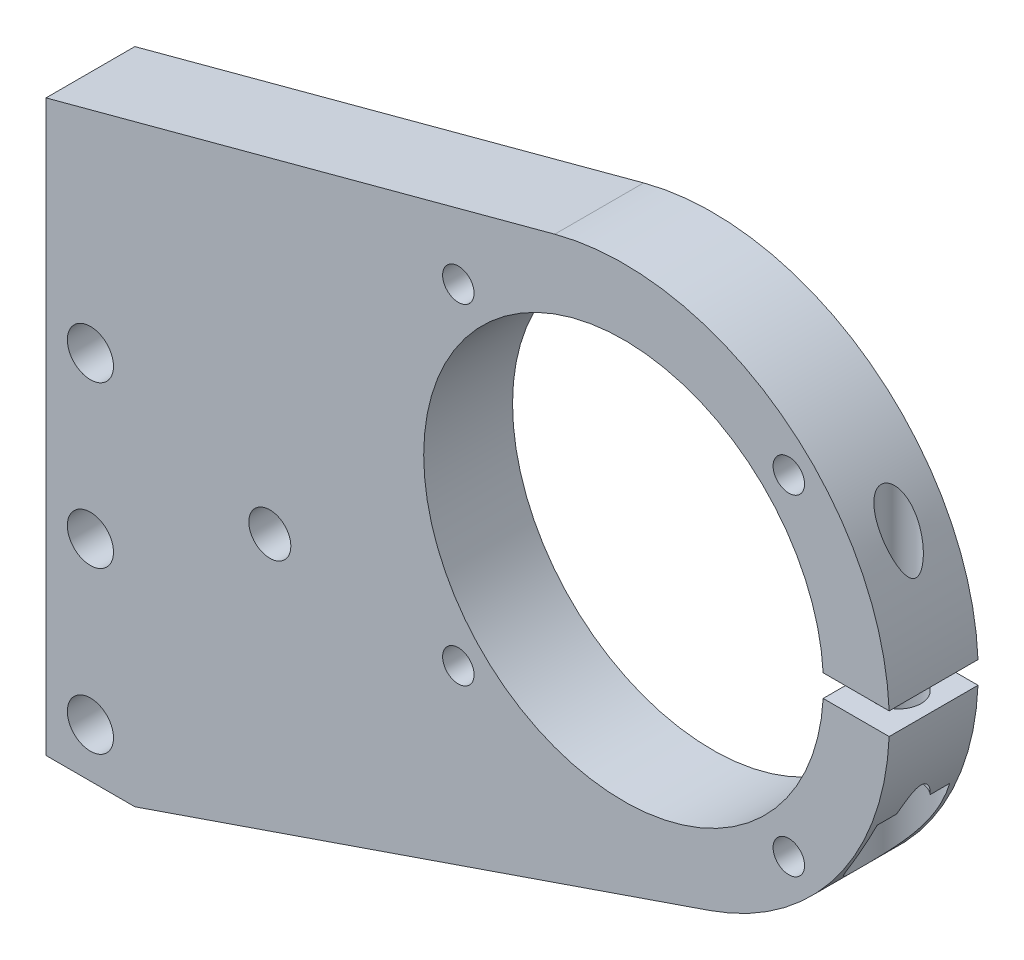
from build123d import *

# Parameters (mm, degrees)
BOSS_EXTRUDE1_DEPTH         = 12.7
CUT_EXTRUDE1_DEPTH          = 13.7
SKETCH3_W                   = 28.575
SKETCH3_H                   = 12.7
F_8_CLEARANCE_HOLE1_D       = 4.5
F_8_CLEARANCE_HOLE1_DEPTH   = 12.7
F_1_4_CLEARANCE_HOLE1_D     = 6.6
F_1_4_CLEARANCE_HOLE1_DEPTH = 12.7
F_12_CLEARANCE_HOLE1_D      = 6
F_12_CLEARANCE_HOLE1_DEPTH  = 12.7
HOLE1_D                     = 6.4
HOLE1_DEPTH                 = 24.77643101
HOLE1_CBORE_D               = 11.2
HOLE1_CBORE_DEPTH           = 11.77643101
F_10_CLEARANCE_HOLE1_D      = 5
F_10_CLEARANCE_HOLE1_DEPTH  = 36.4125
CHAMFER1_SIZE               = 3
SKETCH14_R                  = 4
SKETCH14_R_2                = 3
BOSS_EXTRUDE2_DEPTH         = 12.7


with BuildPart() as part:
    # Sketch1 → Boss-Extrude1 (new body)
    with BuildSketch(Plane(origin=(0, 0, 0), x_dir=(-1, 0, 0), z_dir=(0, 0, -1))):
        with BuildLine():
            Line((224.169455465, 127.72254562), (151.435240745, 147.211619716))
            ThreePointArc((151.435240745, 147.211619716), (105.257753851, 121.607458019), (129.246532787, 74.570537656))
            Line((129.246532787, 74.570537656), (211.469455465, 46.304993078))
            Line((211.469455465, 46.304993078), (224.169455465, 46.304993078))
            Line((224.169455465, 46.304993078), (224.169455465, 127.72254562))
        make_face()
    extrude(amount=-BOSS_EXTRUDE1_DEPTH)

    # Sketch2 → Cut-Extrude1 (cut, through all)
    with BuildSketch(Plane.XY.offset(12.7)):
        with BuildLine():
            Line((-103.633291463, 112.093938317), (-113.179018515, 112.093938317))
            ThreePointArc((-113.179018515, 112.093938317), (-113.134717032, 110.506438317), (-113.179018515, 108.918938317))
            Line((-113.179018515, 108.918938317), (-103.633291463, 108.918938317))
            ThreePointArc((-103.633291463, 108.918938317), (-103.600117032, 110.506438317), (-103.633291463, 112.093938317))
        make_face()
    extrude(amount=-CUT_EXTRUDE1_DEPTH, mode=Mode.SUBTRACT)

    # Sketch3 → Cut-Revolve1 (revolve, cut)
    with BuildSketch(Plane(origin=(0, 110.506438317, 0), x_dir=(1, 0, 0), z_dir=(0, 1, 0))):
        with Locations((-127.312617032, -6.35)):
            Rectangle(SKETCH3_W, SKETCH3_H)
    revolve(axis=Axis((-141.600117032, 110.506438317, 0), (0, 0, 1)), mode=Mode.SUBTRACT)

    # #8 Clearance Hole1
    with Locations(Plane.XY.offset(12.7)):
        with Locations((-117.978117032, 86.884438317), (-165.222117032, 86.884438317), (-165.222117032, 134.128438317), (-117.978117032, 134.128438317)):
            Hole(F_8_CLEARANCE_HOLE1_D / 2, depth=F_8_CLEARANCE_HOLE1_DEPTH)

    # 1/4 Clearance Hole1
    with Locations(Plane(origin=(0, 0, 0), x_dir=(-1, 0, 0), z_dir=(0, 0, -1))):
        with Locations((217.819455465, 53.304993078), (217.819455465, 76.304993078), (217.819455465, 99.304993078)):
            Hole(F_1_4_CLEARANCE_HOLE1_D / 2, depth=F_1_4_CLEARANCE_HOLE1_DEPTH)

    # #12 Clearance Hole1
    with Locations(Plane.XY.offset(12.7)):
        with Locations((-192.169455465, 89.72254562)):
            Hole(F_12_CLEARANCE_HOLE1_D / 2, depth=F_12_CLEARANCE_HOLE1_DEPTH)

    # Hole1
    with Locations(Plane(origin=(0, 84.142507307, 0), x_dir=(-1, 0, 0), z_dir=(0, -1, 0))):
        with Locations((108.633291463, -6.35)):
            CounterBoreHole(HOLE1_D / 2, HOLE1_CBORE_D / 2, HOLE1_CBORE_DEPTH, depth=HOLE1_DEPTH)

    # #10 Clearance Hole1
    with Locations(Plane(origin=(0, 112.093938317, 0), x_dir=(-1, 0, 0), z_dir=(0, -1, 0))):
        with Locations((108.633291463, -6.35)):
            Hole(F_10_CLEARANCE_HOLE1_D / 2, depth=F_10_CLEARANCE_HOLE1_DEPTH)

    # Chamfer1
    chamfer1_edges = [part.edges().sort_by_distance(p)[0] for p in [
        (-221.119455465, 99.304993078, 0),
        (-221.119455465, 76.304993078, 0),
        (-221.119455465, 53.304993078, 0),
    ]]
    chamfer(chamfer1_edges, length=CHAMFER1_SIZE)

    # Sketch14 → Boss-Extrude2 (add)
    with BuildSketch(Plane(origin=(0, 0, 0), x_dir=(-1, 0, 0), z_dir=(0, 0, -1))):
        with Locations((192.169455465, 89.72254562)):
            Circle(SKETCH14_R)
        with Locations((192.169455465, 89.72254562)):
            Circle(SKETCH14_R_2, mode=Mode.SUBTRACT)
    extrude(amount=-BOSS_EXTRUDE2_DEPTH)


solid = part.part
